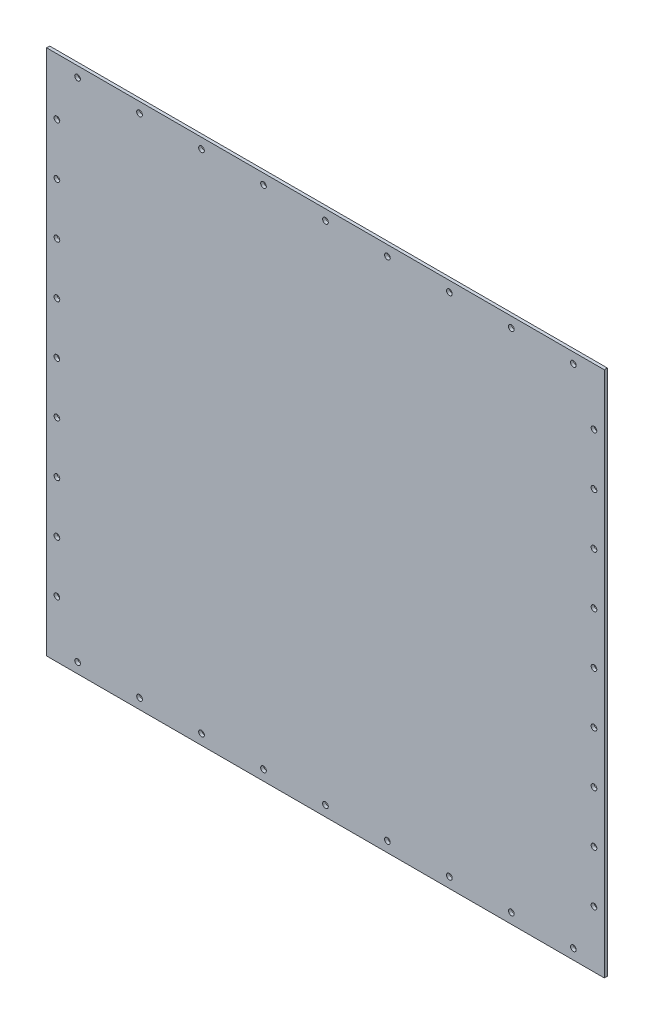
from build123d import *

# Parameters (mm, degrees)
SKETCH1_W            = 540
SKETCH1_H            = 510
BOSS_EXTRUDE1_DEPTH  = 3
M5_CLEARANCE_HOLE1_D = 5.5
LPATTERN1_COUNT      = 5
LPATTERN1_PITCH      = 50
LPATTERN2_COUNT      = 5
LPATTERN2_PITCH      = 50
M5_CLEARANCE_HOLE2_D = 5.5
LPATTERN3_COUNT      = 5
LPATTERN3_PITCH      = 60
LPATTERN4_COUNT      = 5
LPATTERN4_PITCH      = 60
MIRROR1_COPY_1_D     = 5.5
MIRROR1_COPY_2_D     = 5.5
MIRROR1_COPY_3_D     = 5.5
MIRROR1_COPY_4_D     = 5.5
MIRROR1_COPY_5_D     = 5.5
MIRROR1_COPY_6_D     = 5.5
MIRROR1_COPY_7_D     = 5.5
MIRROR1_COPY_8_D     = 5.5
MIRROR2_COPY_1_D     = 5.5
MIRROR2_COPY_2_D     = 5.5
MIRROR2_COPY_3_D     = 5.5
MIRROR2_COPY_4_D     = 5.5
MIRROR2_COPY_5_D     = 5.5
MIRROR2_COPY_6_D     = 5.5
MIRROR2_COPY_7_D     = 5.5
MIRROR2_COPY_8_D     = 5.5


with BuildPart() as part:
    # Sketch1 → Boss-Extrude1 (new body)
    with BuildSketch(Plane.XY):
        with Locations((270, 255)):
            Rectangle(SKETCH1_W, SKETCH1_H)
    extrude(amount=BOSS_EXTRUDE1_DEPTH)

    # M5 Clearance Hole1 (through all)
    with Locations(Plane.XY.offset(3)):
        with Locations((10, 255)):
            m5_clearance_hole1 = Hole(M5_CLEARANCE_HOLE1_D / 2)

    # LPattern1: M5 Clearance Hole1 ×5
    with Locations(*[(0, i * LPATTERN1_PITCH, 0) for i in range(1, LPATTERN1_COUNT)]):
        add(m5_clearance_hole1, mode=Mode.SUBTRACT)

    # LPattern2: M5 Clearance Hole1 ×5
    with Locations(*[(0, -i * LPATTERN2_PITCH, 0) for i in range(1, LPATTERN2_COUNT)]):
        add(m5_clearance_hole1, mode=Mode.SUBTRACT)

    # M5 Clearance Hole2 (through all)
    with Locations(Plane.XY.offset(3)):
        with Locations((270, 10)):
            m5_clearance_hole2 = Hole(M5_CLEARANCE_HOLE2_D / 2)

    # LPattern3: M5 Clearance Hole2 ×5
    with Locations(*[(i * LPATTERN3_PITCH, 0, 0) for i in range(1, LPATTERN3_COUNT)]):
        add(m5_clearance_hole2, mode=Mode.SUBTRACT)

    # LPattern4: M5 Clearance Hole2 ×5
    with Locations(*[(-i * LPATTERN4_PITCH, 0, 0) for i in range(1, LPATTERN4_COUNT)]):
        add(m5_clearance_hole2, mode=Mode.SUBTRACT)

    # Mirror1: M5 Clearance Hole2 across plane
    add(m5_clearance_hole2.mirror(Plane.ZX.offset(255)), mode=Mode.SUBTRACT)

    # Mirror1 copy 1 (through all)
    with Locations(Plane(origin=(60, 510, 3), x_dir=(1, 0, 0), z_dir=(0, 0, 1))):
        with Locations((270, -10)):
            Hole(MIRROR1_COPY_1_D / 2)

    # Mirror1 copy 2 (through all)
    with Locations(Plane(origin=(120, 510, 3), x_dir=(1, 0, 0), z_dir=(0, 0, 1))):
        with Locations((270, -10)):
            Hole(MIRROR1_COPY_2_D / 2)

    # Mirror1 copy 3 (through all)
    with Locations(Plane(origin=(180, 510, 3), x_dir=(1, 0, 0), z_dir=(0, 0, 1))):
        with Locations((270, -10)):
            Hole(MIRROR1_COPY_3_D / 2)

    # Mirror1 copy 4 (through all)
    with Locations(Plane(origin=(240, 510, 3), x_dir=(1, 0, 0), z_dir=(0, 0, 1))):
        with Locations((270, -10)):
            Hole(MIRROR1_COPY_4_D / 2)

    # Mirror1 copy 5 (through all)
    with Locations(Plane(origin=(-60, 510, 3), x_dir=(1, 0, 0), z_dir=(0, 0, 1))):
        with Locations((270, -10)):
            Hole(MIRROR1_COPY_5_D / 2)

    # Mirror1 copy 6 (through all)
    with Locations(Plane(origin=(-120, 510, 3), x_dir=(1, 0, 0), z_dir=(0, 0, 1))):
        with Locations((270, -10)):
            Hole(MIRROR1_COPY_6_D / 2)

    # Mirror1 copy 7 (through all)
    with Locations(Plane(origin=(-180, 510, 3), x_dir=(1, 0, 0), z_dir=(0, 0, 1))):
        with Locations((270, -10)):
            Hole(MIRROR1_COPY_7_D / 2)

    # Mirror1 copy 8 (through all)
    with Locations(Plane(origin=(-240, 510, 3), x_dir=(1, 0, 0), z_dir=(0, 0, 1))):
        with Locations((270, -10)):
            Hole(MIRROR1_COPY_8_D / 2)

    # Mirror2: M5 Clearance Hole1 across plane
    add(m5_clearance_hole1.mirror(Plane.ZY.offset(-270)), mode=Mode.SUBTRACT)

    # Mirror2 copy 1 (through all)
    with Locations(Plane(origin=(540, 50, 3), x_dir=(-1, 0, 0), z_dir=(0, 0, 1))):
        with Locations((10, -255)):
            Hole(MIRROR2_COPY_1_D / 2)

    # Mirror2 copy 2 (through all)
    with Locations(Plane(origin=(540, 100, 3), x_dir=(-1, 0, 0), z_dir=(0, 0, 1))):
        with Locations((10, -255)):
            Hole(MIRROR2_COPY_2_D / 2)

    # Mirror2 copy 3 (through all)
    with Locations(Plane(origin=(540, 150, 3), x_dir=(-1, 0, 0), z_dir=(0, 0, 1))):
        with Locations((10, -255)):
            Hole(MIRROR2_COPY_3_D / 2)

    # Mirror2 copy 4 (through all)
    with Locations(Plane(origin=(540, 200, 3), x_dir=(-1, 0, 0), z_dir=(0, 0, 1))):
        with Locations((10, -255)):
            Hole(MIRROR2_COPY_4_D / 2)

    # Mirror2 copy 5 (through all)
    with Locations(Plane(origin=(540, -50, 3), x_dir=(-1, 0, 0), z_dir=(0, 0, 1))):
        with Locations((10, -255)):
            Hole(MIRROR2_COPY_5_D / 2)

    # Mirror2 copy 6 (through all)
    with Locations(Plane(origin=(540, -100, 3), x_dir=(-1, 0, 0), z_dir=(0, 0, 1))):
        with Locations((10, -255)):
            Hole(MIRROR2_COPY_6_D / 2)

    # Mirror2 copy 7 (through all)
    with Locations(Plane(origin=(540, -150, 3), x_dir=(-1, 0, 0), z_dir=(0, 0, 1))):
        with Locations((10, -255)):
            Hole(MIRROR2_COPY_7_D / 2)

    # Mirror2 copy 8 (through all)
    with Locations(Plane(origin=(540, -200, 3), x_dir=(-1, 0, 0), z_dir=(0, 0, 1))):
        with Locations((10, -255)):
            Hole(MIRROR2_COPY_8_D / 2)


solid = part.part
